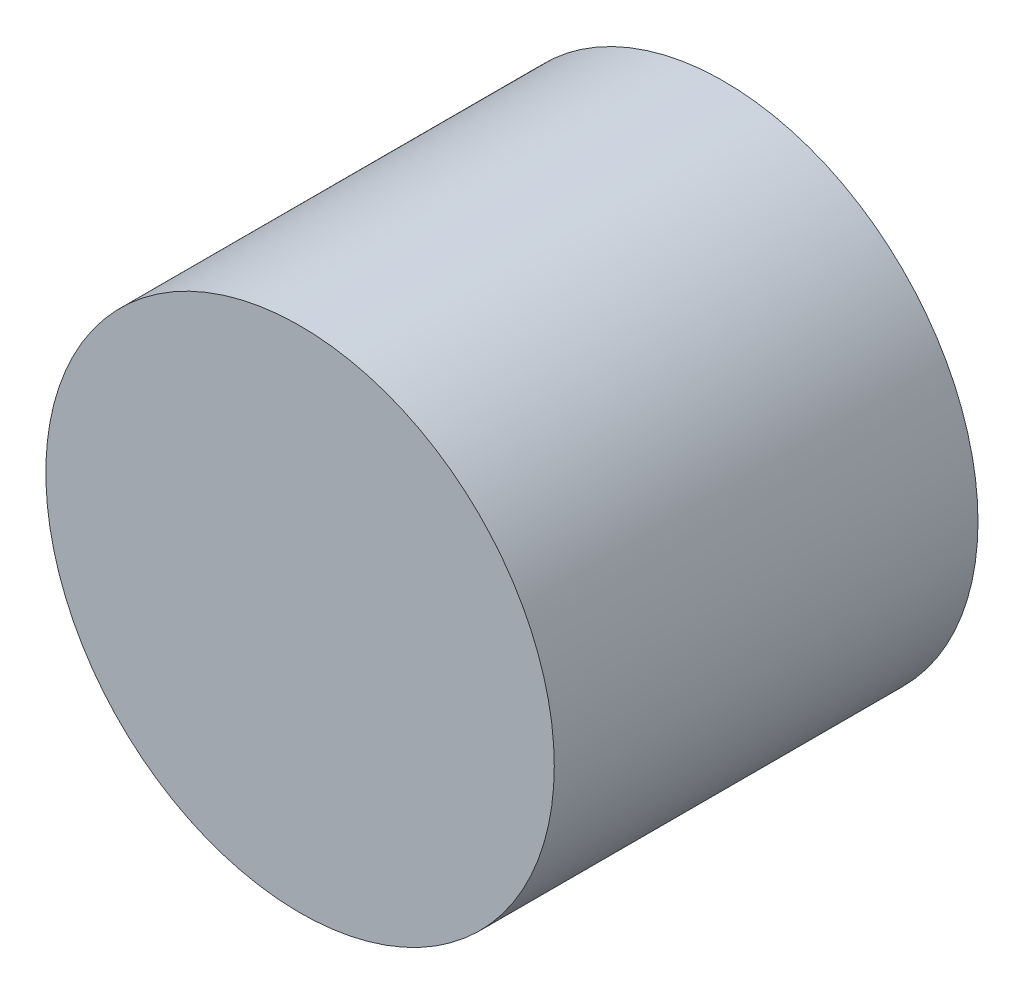
from build123d import *

# Parameters (mm, degrees)
SKETCH1_R           = 6
BOSS_EXTRUDE1_DEPTH = 10


with BuildPart() as part:
    # Sketch1 → Boss-Extrude1 (new body)
    with BuildSketch(Plane(origin=(0, 0, 0), x_dir=(0, 1, 0), z_dir=(0, 0, 1))):
        Circle(SKETCH1_R)
    extrude(amount=BOSS_EXTRUDE1_DEPTH)


solid = part.part
